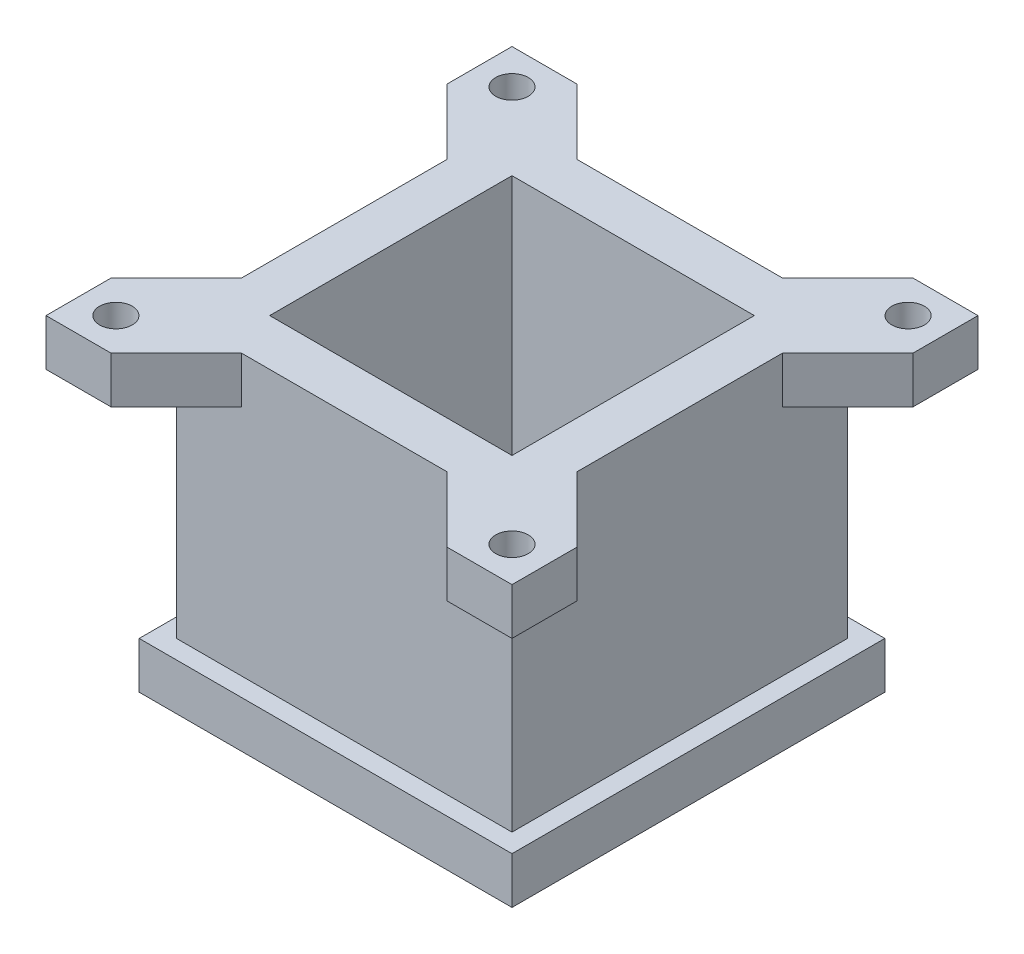
from build123d import *

# Parameters (mm, degrees)
SKETCH4_W           = 40
SKETCH4_H           = 40
BOSS_EXTRUDE3_DEPTH = 5
SKETCH1_W           = 36
SKETCH1_H           = 36
SKETCH1_W_2         = 26
SKETCH1_H_2         = 26
BOSS_EXTRUDE4_DEPTH = 35
SKETCH9_W           = 50
SKETCH9_H           = 50
SKETCH9_W_2         = 26
SKETCH9_H_2         = 26
BOSS_EXTRUDE6_DEPTH = 5
SKETCH10_R          = 1.75
CUT_EXTRUDE2_DEPTH  = 10
CUT_EXTRUDE3_DEPTH  = 10


with BuildPart() as part:
    # Sketch4 → Boss-Extrude3 (new body)
    with BuildSketch(Plane(origin=(0, 0, 0), x_dir=(1, 0, 0), z_dir=(0, 1, 0))):
        Rectangle(SKETCH4_W, SKETCH4_H)
        Polygon((-2.5, -8.525), (-2.5, -13), (-13, -13), (-13, -2.5), (-8.400446417, -2.5), (-4.921911045, -8.525), align=None, mode=Mode.SUBTRACT)
        Polygon((7.534421013, 0), (3.767210506, 6.525), (-3.767210506, 6.525), (-7.534421013, 0), (-3.767210506, -6.525), (3.767210506, -6.525), align=None, mode=Mode.SUBTRACT)
        Polygon((13, 13), (2.5, 13), (2.5, 8.525), (4.921911045, 8.525), (8.400446417, 2.5), (13, 2.5), align=None, mode=Mode.SUBTRACT)
        Polygon((13, -13), (2.5, -13), (2.5, -8.525), (4.921911045, -8.525), (8.400446417, -2.5), (13, -2.5), align=None, mode=Mode.SUBTRACT)
        Polygon((-13, 13), (-13, 2.5), (-8.400446417, 2.5), (-4.921911045, 8.525), (-2.5, 8.525), (-2.5, 13), align=None, mode=Mode.SUBTRACT)
    extrude(amount=BOSS_EXTRUDE3_DEPTH)

    # Sketch1 → Boss-Extrude4 (add)
    with BuildSketch(Plane(origin=(0, 0, 0), x_dir=(1, 0, 0), z_dir=(0, 1, 0))):
        Rectangle(SKETCH1_W, SKETCH1_H)
        Rectangle(SKETCH1_W_2, SKETCH1_H_2, mode=Mode.SUBTRACT)
    extrude(amount=BOSS_EXTRUDE4_DEPTH)

    # Sketch9 → Boss-Extrude6 (add)
    with BuildSketch(Plane(origin=(0, 30, 0), x_dir=(1, 0, 0), z_dir=(0, 1, 0))):
        Rectangle(SKETCH9_W, SKETCH9_H)
        Rectangle(SKETCH9_W_2, SKETCH9_H_2, mode=Mode.SUBTRACT)
    extrude(amount=BOSS_EXTRUDE6_DEPTH)

    # Sketch10 → Cut-Extrude2 (cut)
    with BuildSketch(Plane(origin=(0, 25, 0), x_dir=(1, 0, 0), z_dir=(0, 1, 0))):
        with Locations((-21.25, 21.25)):
            Circle(SKETCH10_R)
        with Locations((21.25, 21.25)):
            Circle(SKETCH10_R)
        with Locations((21.25, -21.25)):
            Circle(SKETCH10_R)
        with Locations((-21.25, -21.25)):
            Circle(SKETCH10_R)
    extrude(amount=CUT_EXTRUDE2_DEPTH, mode=Mode.SUBTRACT)

    # Sketch11 → Cut-Extrude3 (cut)
    with BuildSketch(Plane(origin=(0, 25, 0), x_dir=(1, 0, 0), z_dir=(0, 1, 0))):
        Polygon((11, 18), (-11, 18), (-18, 25), (18, 25), align=None)
        Polygon((18, 11), (18, -11), (25, -18), (25, 18), align=None)
        Polygon((11, -18), (-11, -18), (-18, -25), (18, -25), align=None)
        Polygon((-18, 11), (-18, -11), (-25, -18), (-25, 18), align=None)
    extrude(amount=CUT_EXTRUDE3_DEPTH, mode=Mode.SUBTRACT)


solid = part.part
